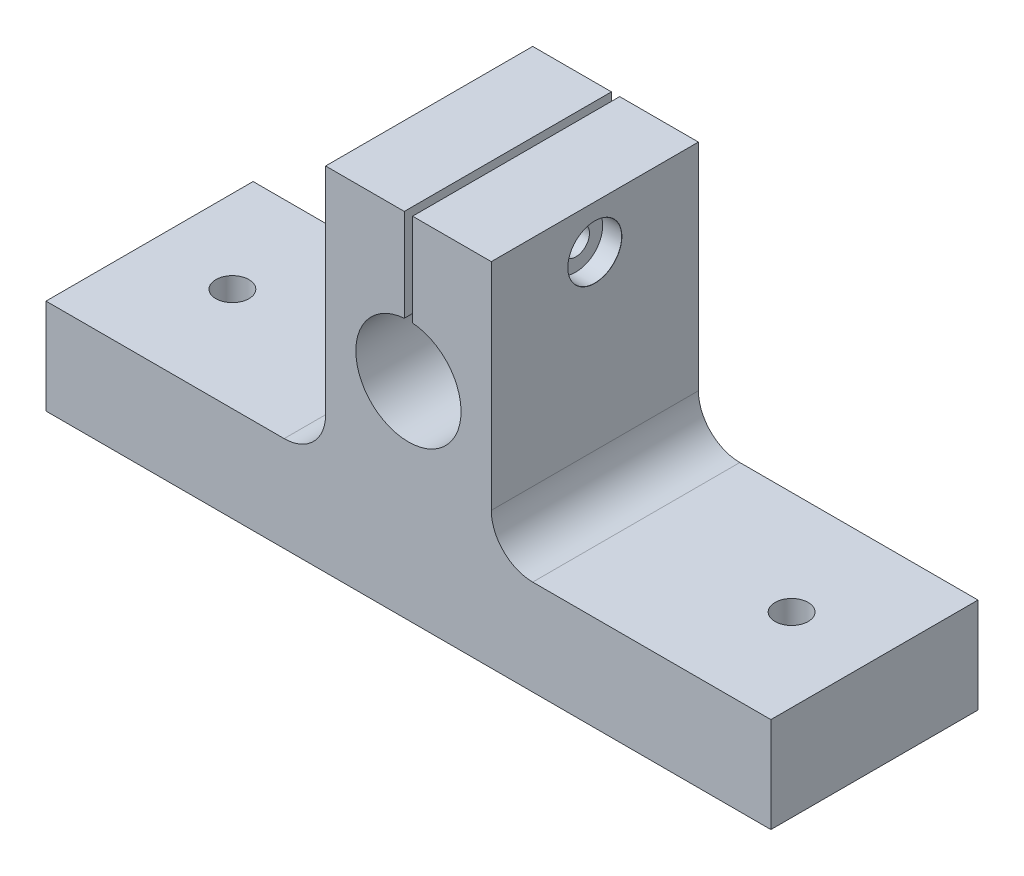
from build123d import *

# Parameters (mm, degrees)
RESSALTO_EXTRUS_O1_DEPTH = 50
ESBO_O2_R                = 4
CORTE_EXTRUS_O1_DEPTH    = 24
CORTE_EXTRUS_O2_DEPTH    = 51
FILETE1_R                = 10


with BuildPart() as part:
    # Esboço1 → Ressalto-extrusão1 (new body)
    with BuildSketch(Plane.XY):
        Polygon((87.5, 0), (-87.5, 0), (-87.5, 23), (-20, 23), (-20, 85), (20, 85), (20, 23), (87.5, 23), align=None)
    extrude(amount=RESSALTO_EXTRUS_O1_DEPTH)

    # Esboço2 → Corte-extrusão1 (cut, through all)
    with BuildSketch(Plane(origin=(0, 23, 0), x_dir=(1, 0, 0), z_dir=(0, 1, 0))):
        with Locations((-67.5, -25)):
            Circle(ESBO_O2_R)
        with Locations((67.5, -25)):
            Circle(ESBO_O2_R)
    extrude(amount=-CORTE_EXTRUS_O1_DEPTH, mode=Mode.SUBTRACT)

    # Esboço3 → Corte-extrusão2 (cut, through all)
    with BuildSketch(Plane.XY.offset(50)):
        with BuildLine():
            Line((1, 62.660568708), (1, 116.5))
            Line((1, 116.5), (-1, 116.5))
            Line((-1, 116.5), (-1, 62.660568708))
            ThreePointArc((-1, 62.660568708), (0, 37.3), (1, 62.660568708))
        make_face()
    extrude(amount=-CORTE_EXTRUS_O2_DEPTH, mode=Mode.SUBTRACT)

    # Filete1
    filete1_edges = [part.edges().sort_by_distance(p)[0] for p in [
        (-20, 23, 25),
        (20, 23, 25),
    ]]
    fillet(filete1_edges, radius=FILETE1_R)

    # Esboço5 → Rebaixo para parafuso de máquina com cabeça panela de M61 (revolve, cut)
    with BuildSketch(Plane(origin=(20, 74.5, 25), x_dir=(0, 0, -1), z_dir=(0, 1, 0))):
        Polygon((0, 0), (0, 107.5), (3.3, 107.5), (3.3, 4.6), (6.5, 4.6), (6.5, 0.025), (6.525, 0), align=None)
    revolve(axis=Axis((26.35, 74.5, 25), (-1, 0, 0)), mode=Mode.SUBTRACT)


solid = part.part
